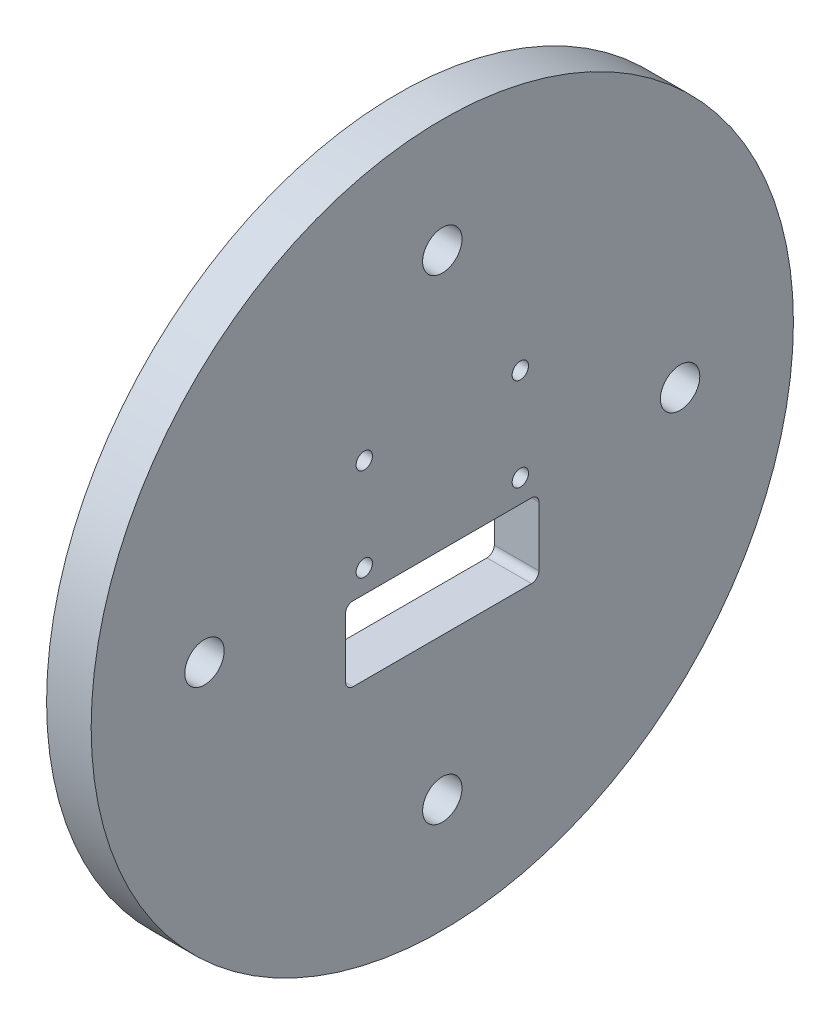
from build123d import *

# Parameters (mm, degrees)
SKETCH1_R                = 47.25
BOSS_EXTRUDE1_DEPTH      = 6
SKETCH2_R                = 1.1
CUT_EXTRUDE1_DEPTH       = 20
M5_CLEARANCE_HOLE1_D     = 5.3
M5_CLEARANCE_HOLE1_DEPTH = 15
M5_CLEARANCE_HOLE1_TIP   = 1.59228064


with BuildPart() as part:
    # Sketch1 → Boss-Extrude1 (new body)
    with BuildSketch(Plane(origin=(0, 0, 0), x_dir=(0, 0, -1), z_dir=(1, 0, 0))):
        Circle(SKETCH1_R)
    extrude(amount=BOSS_EXTRUDE1_DEPTH)

    # Sketch2 → Cut-Extrude1 (cut)
    with BuildSketch(Plane(origin=(6, 0, 0), x_dir=(0, 0, -1), z_dir=(1, 0, 0))):
        with BuildLine():
            Line((12, -2.85), (-12, -2.85))
            ThreePointArc((-12, -2.85), (-12.812754403, -3.224796478), (-13, -4.1))
            Line((-13, -4.1), (-13, -11.85))
            ThreePointArc((-13, -11.85), (-12.707106781, -12.557106781), (-12, -12.85))
            Line((-12, -12.85), (12, -12.85))
            ThreePointArc((12, -12.85), (12.707106781, -12.557106781), (13, -11.85))
            Line((13, -11.85), (13, -3.85))
            ThreePointArc((13, -3.85), (12.707106781, -3.142893219), (12, -2.85))
        make_face()
        with Locations((-10.5, 12.75)):
            Circle(SKETCH2_R)
        with Locations((10.5, 12.75)):
            Circle(SKETCH2_R)
        with Locations((10.5, 0.25)):
            Circle(SKETCH2_R)
        with Locations((-10.5, 0.25)):
            Circle(SKETCH2_R)
    extrude(amount=-CUT_EXTRUDE1_DEPTH, mode=Mode.SUBTRACT)

    # M5 Clearance Hole1
    with Locations(Plane(origin=(6, 0, 0), x_dir=(0, 0, -1), z_dir=(1, 0, 0))):
        with Locations((-32, 0), (0, 32), (32, 0), (0, -32)):
            Hole(M5_CLEARANCE_HOLE1_D / 2, depth=M5_CLEARANCE_HOLE1_DEPTH)
            with Locations((0, 0, -(M5_CLEARANCE_HOLE1_DEPTH + M5_CLEARANCE_HOLE1_TIP / 2))):  # 118° drill point
                Cone(0, M5_CLEARANCE_HOLE1_D / 2, M5_CLEARANCE_HOLE1_TIP, mode=Mode.SUBTRACT)


solid = part.part
